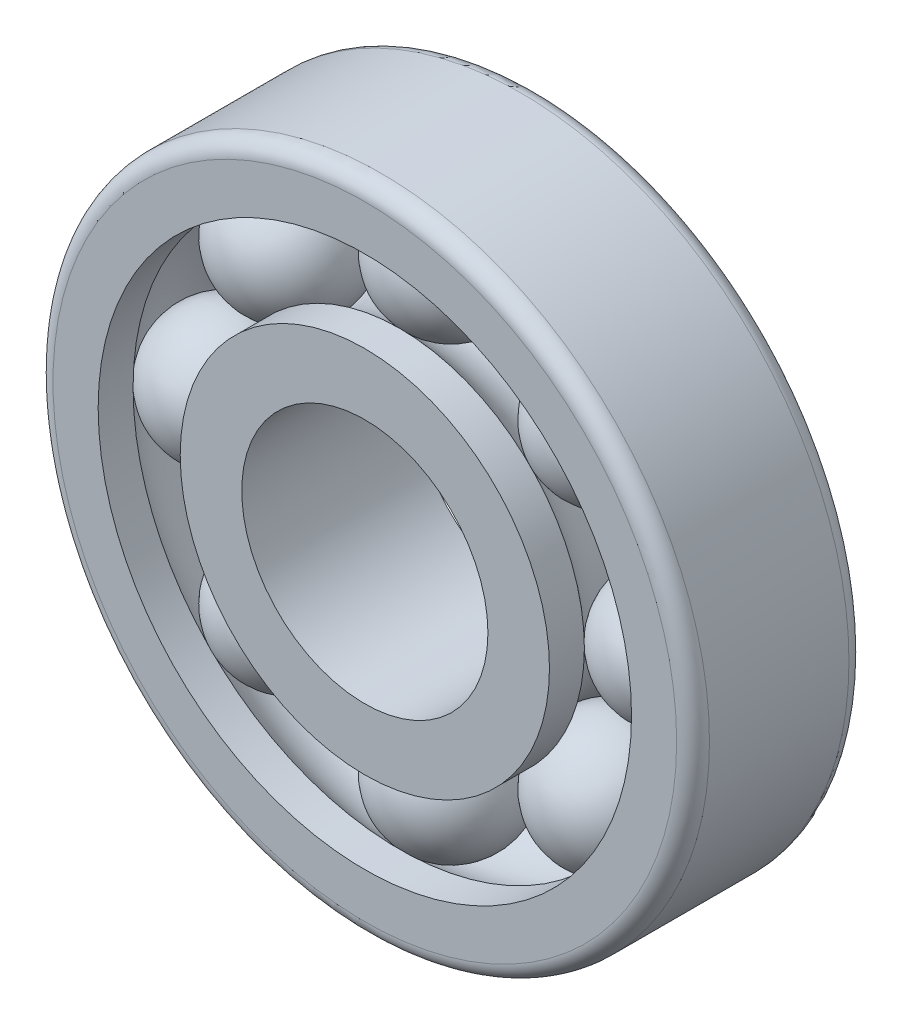
from build123d import *

# Parameters (mm, degrees)
SKETCH1_R             = 40
SKETCH1_R_2           = 32.5
BOSS_EXTRUDE1_DEPTH   = 21
SKETCH1_R_3           = 22.5
SKETCH1_R_4           = 15
BOSS_EXTRUDE1_2_DEPTH = 21
SKETCH2_R             = 8
CIRPATTERN1_COUNT     = 8
FILLET1_R             = 2


with BuildPart() as part:
    # Sketch1 → Boss-Extrude1 (new body)
    with BuildSketch(Plane.XY):
        Circle(SKETCH1_R)
        Circle(SKETCH1_R_2, mode=Mode.SUBTRACT)
    extrude(amount=BOSS_EXTRUDE1_DEPTH)


with BuildPart() as body_2:
    # Sketch1 → Boss-Extrude1 2 (new body)
    with BuildSketch(Plane.XY):
        Circle(SKETCH1_R_3)
        Circle(SKETCH1_R_4, mode=Mode.SUBTRACT)
    extrude(amount=BOSS_EXTRUDE1_2_DEPTH)


with BuildPart() as cut_revolve1_tool:
    # Sketch2 → Cut-Revolve1 (revolve)
    with BuildSketch(Plane(origin=(0, 0, 0), x_dir=(1, 0, 0), z_dir=(0, 1, 0))):
        with Locations((27.5, -10.5)):
            Circle(SKETCH2_R)
    revolve(axis=Axis((0, 0, 0), (0, 0, -1)))


with BuildPart() as part_1:
    add(part.part)

    # Cut-Revolve1: cut by cut_revolve1_tool
    add(cut_revolve1_tool.part, mode=Mode.SUBTRACT)

    # Fillet1
    fillet1_edges = [part_1.edges().sort_by_distance(p)[0] for p in [
        (-40, 0, 21),
        (-40, 0, 0),
    ]]
    fillet(fillet1_edges, radius=FILLET1_R)


with BuildPart() as body_2_1:
    add(body_2.part)

    # Cut-Revolve1: cut by cut_revolve1_tool
    add(cut_revolve1_tool.part, mode=Mode.SUBTRACT)


with BuildPart() as body_3:
    # Sketch3 → Revolve1 (revolve)
    with BuildSketch(Plane(origin=(0, 0, 0), x_dir=(1, 0, 0), z_dir=(0, 1, 0))):
        with BuildLine():
            Line((27.5, -2.5), (27.5, -18.5))
            ThreePointArc((27.5, -18.5), (35.5, -10.5), (27.5, -2.5))
        make_face()
    revolve(axis=Axis((27.5, 0, 2.5), (0, 0, 1)))


with BuildPart() as cirpattern1_1:
    # CirPattern1: pattern copy
    add(body_3.part.rotate(Axis((0, 0, 0), (0, 0, 1)), 1 * 360 / CIRPATTERN1_COUNT))


with BuildPart() as cirpattern1_2:
    # CirPattern1: pattern copy
    add(body_3.part.rotate(Axis((0, 0, 0), (0, 0, 1)), 2 * 360 / CIRPATTERN1_COUNT))


with BuildPart() as cirpattern1_3:
    # CirPattern1: pattern copy
    add(body_3.part.rotate(Axis((0, 0, 0), (0, 0, 1)), 3 * 360 / CIRPATTERN1_COUNT))


with BuildPart() as cirpattern1_4:
    # CirPattern1: pattern copy
    add(body_3.part.rotate(Axis((0, 0, 0), (0, 0, 1)), 4 * 360 / CIRPATTERN1_COUNT))


with BuildPart() as cirpattern1_5:
    # CirPattern1: pattern copy
    add(body_3.part.rotate(Axis((0, 0, 0), (0, 0, 1)), 5 * 360 / CIRPATTERN1_COUNT))


with BuildPart() as cirpattern1_6:
    # CirPattern1: pattern copy
    add(body_3.part.rotate(Axis((0, 0, 0), (0, 0, 1)), 6 * 360 / CIRPATTERN1_COUNT))


with BuildPart() as cirpattern1_7:
    # CirPattern1: pattern copy
    add(body_3.part.rotate(Axis((0, 0, 0), (0, 0, 1)), 7 * 360 / CIRPATTERN1_COUNT))


solid = Compound([part_1.part, body_2_1.part, body_3.part, cirpattern1_1.part, cirpattern1_2.part, cirpattern1_3.part, cirpattern1_4.part, cirpattern1_5.part, cirpattern1_6.part, cirpattern1_7.part])
